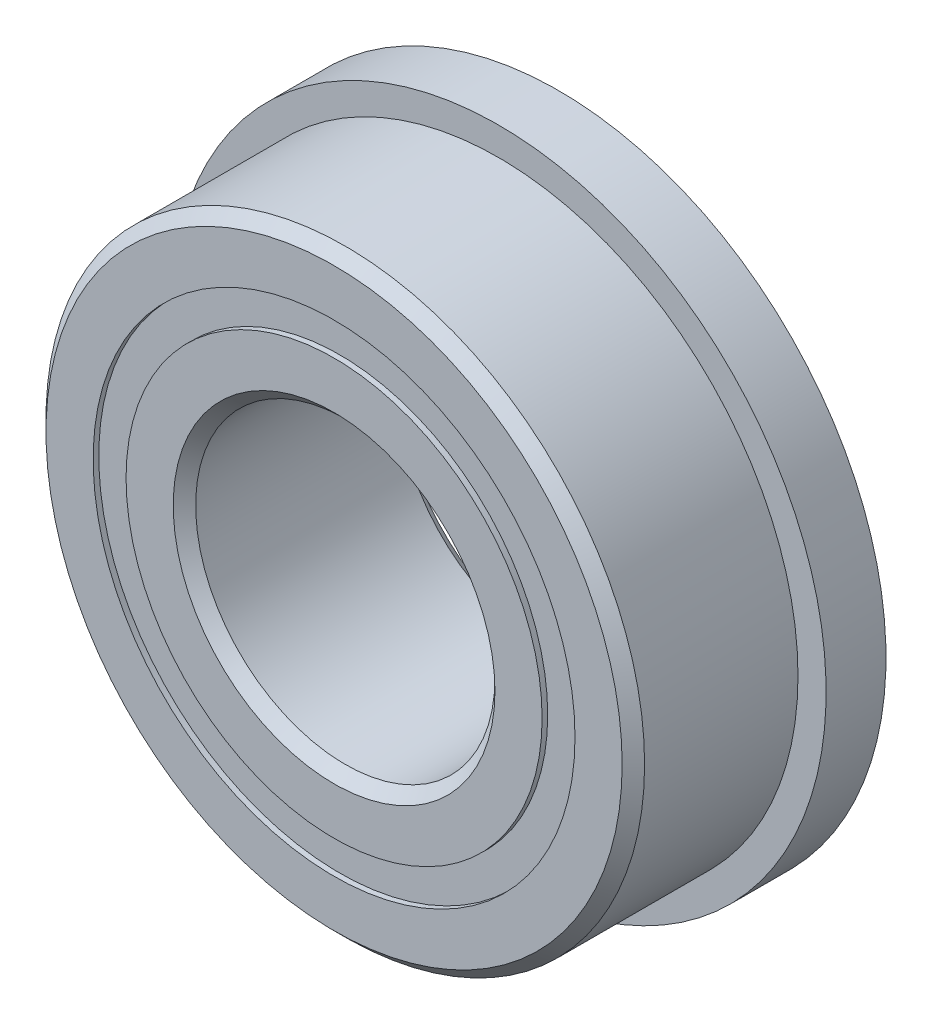
from build123d import *

# Parameters (mm, degrees)
CIRPATTERN1_COUNT = 12
SKETCH5_W         = 1.147826059
SKETCH5_H         = 0.697802198
SKETCH6_W         = 1.27
SKETCH6_H         = 1.835498901


with BuildPart() as part:
    # Sketch → Revolve1 (revolve)
    with BuildSketch(Plane(origin=(0, 0, 0), x_dir=(0, 0, -1), z_dir=(1, 0, 0))):
        with BuildLine():
            Line((2.143125, 6.35), (-2.143125, 6.35))
            Line((-2.143125, 6.35), (-2.38125, 6.111875))
            Line((-2.38125, 6.111875), (-2.38125, 5.111401099))
            Line((-2.38125, 5.111401099), (-1.058333333, 5.111401099))
            ThreePointArc((-1.058333333, 5.111401099), (0, 5.876861441), (1.058333333, 5.111401099))
            Line((1.058333333, 5.111401099), (2.38125, 5.111401099))
            Line((2.38125, 5.111401099), (2.38125, 6.111875))
            Line((2.38125, 6.111875), (2.143125, 6.35))
        make_face()
    revolve(axis=Axis((0, 0, 2.38125), (0, 0, -1)))

    # Sketch6 → Revolve6 (revolve)
    with BuildSketch(Plane(origin=(0, 0, 0), x_dir=(0, 0, -1), z_dir=(1, 0, 0))):
        with Locations((1.74625, 6.02915055)):
            Rectangle(SKETCH6_W, SKETCH6_H)
    revolve(axis=Axis((0, 0, -2.38125), (0, 0, 1)))


with BuildPart() as body_2:
    # Sketch3 → Revolve3 (revolve)
    with BuildSketch(Plane(origin=(0, 0, 0), x_dir=(0, 0, -1), z_dir=(1, 0, 0))):
        with BuildLine():
            Line((-2.38125, 4.413598901), (-1.058333333, 4.413598901))
            ThreePointArc((-1.058333333, 4.413598901), (0, 3.648138559), (1.058333333, 4.413598901))
            Line((1.058333333, 4.413598901), (2.38125, 4.413598901))
            Line((2.38125, 4.413598901), (2.38125, 3.413125))
            Line((2.38125, 3.413125), (2.143125, 3.175))
            Line((2.143125, 3.175), (-2.143125, 3.175))
            Line((-2.143125, 3.175), (-2.38125, 3.413125))
            Line((-2.38125, 3.413125), (-2.38125, 4.413598901))
        make_face()
    revolve(axis=Axis((0, 0, 2.38125), (0, 0, -1)))


with BuildPart() as body_3:
    # Sketch4 → Revolve4 (revolve)
    with BuildSketch(Plane(origin=(0, 0, 0), x_dir=(0, 0, -1), z_dir=(1, 0, 0))):
        with BuildLine():
            Line((-1.114361441, 4.7625), (1.114361441, 4.7625))
            ThreePointArc((1.114361441, 4.7625), (0, 5.876861441), (-1.114361441, 4.7625))
        make_face()
    revolve(axis=Axis((0, 4.7625, 1.114361441), (0, 0, -1)))


with BuildPart() as cirpattern1_1:
    # CirPattern1: pattern copy
    add(body_3.part.rotate(Axis((0, 0, -2.38125), (0, 0, 1)), 1 * 360 / CIRPATTERN1_COUNT))


with BuildPart() as cirpattern1_2:
    # CirPattern1: pattern copy
    add(body_3.part.rotate(Axis((0, 0, -2.38125), (0, 0, 1)), 2 * 360 / CIRPATTERN1_COUNT))


with BuildPart() as cirpattern1_3:
    # CirPattern1: pattern copy
    add(body_3.part.rotate(Axis((0, 0, -2.38125), (0, 0, 1)), 3 * 360 / CIRPATTERN1_COUNT))


with BuildPart() as cirpattern1_4:
    # CirPattern1: pattern copy
    add(body_3.part.rotate(Axis((0, 0, -2.38125), (0, 0, 1)), 4 * 360 / CIRPATTERN1_COUNT))


with BuildPart() as cirpattern1_5:
    # CirPattern1: pattern copy
    add(body_3.part.rotate(Axis((0, 0, -2.38125), (0, 0, 1)), 5 * 360 / CIRPATTERN1_COUNT))


with BuildPart() as cirpattern1_6:
    # CirPattern1: pattern copy
    add(body_3.part.rotate(Axis((0, 0, -2.38125), (0, 0, 1)), 6 * 360 / CIRPATTERN1_COUNT))


with BuildPart() as cirpattern1_7:
    # CirPattern1: pattern copy
    add(body_3.part.rotate(Axis((0, 0, -2.38125), (0, 0, 1)), 7 * 360 / CIRPATTERN1_COUNT))


with BuildPart() as cirpattern1_8:
    # CirPattern1: pattern copy
    add(body_3.part.rotate(Axis((0, 0, -2.38125), (0, 0, 1)), 8 * 360 / CIRPATTERN1_COUNT))


with BuildPart() as cirpattern1_9:
    # CirPattern1: pattern copy
    add(body_3.part.rotate(Axis((0, 0, -2.38125), (0, 0, 1)), 9 * 360 / CIRPATTERN1_COUNT))


with BuildPart() as cirpattern1_10:
    # CirPattern1: pattern copy
    add(body_3.part.rotate(Axis((0, 0, -2.38125), (0, 0, 1)), 10 * 360 / CIRPATTERN1_COUNT))


with BuildPart() as cirpattern1_11:
    # CirPattern1: pattern copy
    add(body_3.part.rotate(Axis((0, 0, -2.38125), (0, 0, 1)), 11 * 360 / CIRPATTERN1_COUNT))


with BuildPart() as body_15:
    # Sketch5 → Revolve5 (revolve)
    with BuildSketch(Plane(origin=(0, 0, 0), x_dir=(0, 0, -1), z_dir=(1, 0, 0))):
        with Locations((-1.688274471, 4.7625)):
            Rectangle(SKETCH5_W, SKETCH5_H)
        with Locations((1.688274471, 4.7625)):
            Rectangle(SKETCH5_W, SKETCH5_H)
    revolve(axis=Axis((0, 0, 2.38125), (0, 0, -1)))


solid = Compound([part.part, body_2.part, body_3.part, cirpattern1_1.part, cirpattern1_2.part, cirpattern1_3.part, cirpattern1_4.part, cirpattern1_5.part, cirpattern1_6.part, cirpattern1_7.part, cirpattern1_8.part, cirpattern1_9.part, cirpattern1_10.part, cirpattern1_11.part, body_15.part])
